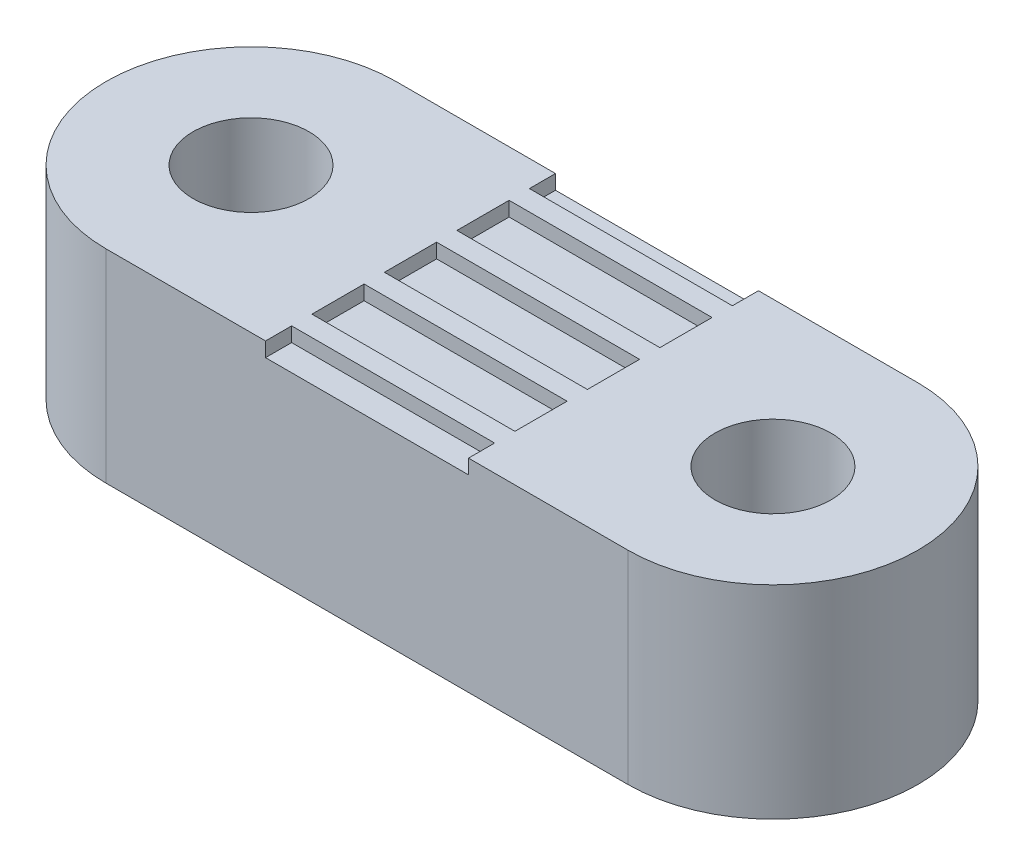
from build123d import *

# Parameters (mm, degrees)
SKETCH1_R           = 2
BOSS_EXTRUDE1_DEPTH = 7
SKETCH2_W           = 7
SKETCH2_H           = 1.8
CUT_EXTRUDE1_DEPTH  = 0.5
LPATTERN1_COUNT     = 3
LPATTERN1_PITCH     = 2.5
LPATTERN1_COL_COUNT = 3
LPATTERN1_COL_PITCH = 2.5


with BuildPart() as part:
    # Sketch1 → Boss-Extrude1 (new body)
    with BuildSketch(Plane(origin=(0, 0, 0), x_dir=(1, 0, 0), z_dir=(0, 1, 0))):
        with BuildLine():
            Line((-9, 5), (9, 5))
            ThreePointArc((9, 5), (14, 0), (9, -5))
            Line((9, -5), (-9, -5))
            ThreePointArc((-9, -5), (-14, 0), (-9, 5))
        make_face()
        with Locations((-9, 0)):
            Circle(SKETCH1_R, mode=Mode.SUBTRACT)
        with Locations((9, 0)):
            Circle(SKETCH1_R, mode=Mode.SUBTRACT)
    extrude(amount=BOSS_EXTRUDE1_DEPTH)

    # Sketch2 → Cut-Extrude1 (cut)
    with BuildSketch(Plane(origin=(0, 7, 0), x_dir=(1, 0, 0), z_dir=(0, 1, 0))):
        Rectangle(SKETCH2_W, SKETCH2_H)
    cut_extrude1 = extrude(amount=-CUT_EXTRUDE1_DEPTH, mode=Mode.SUBTRACT)

    # LPattern1: Cut-Extrude1 ×3
    with Locations(*[(0, 0, i * LPATTERN1_PITCH) for i in range(1, LPATTERN1_COUNT)]):
        add(cut_extrude1, mode=Mode.SUBTRACT)

    # LPattern1 col: Cut-Extrude1 ×3
    with Locations(*[(0, 0, -i * LPATTERN1_COL_PITCH) for i in range(1, LPATTERN1_COL_COUNT)]):
        add(cut_extrude1, mode=Mode.SUBTRACT)


solid = part.part
